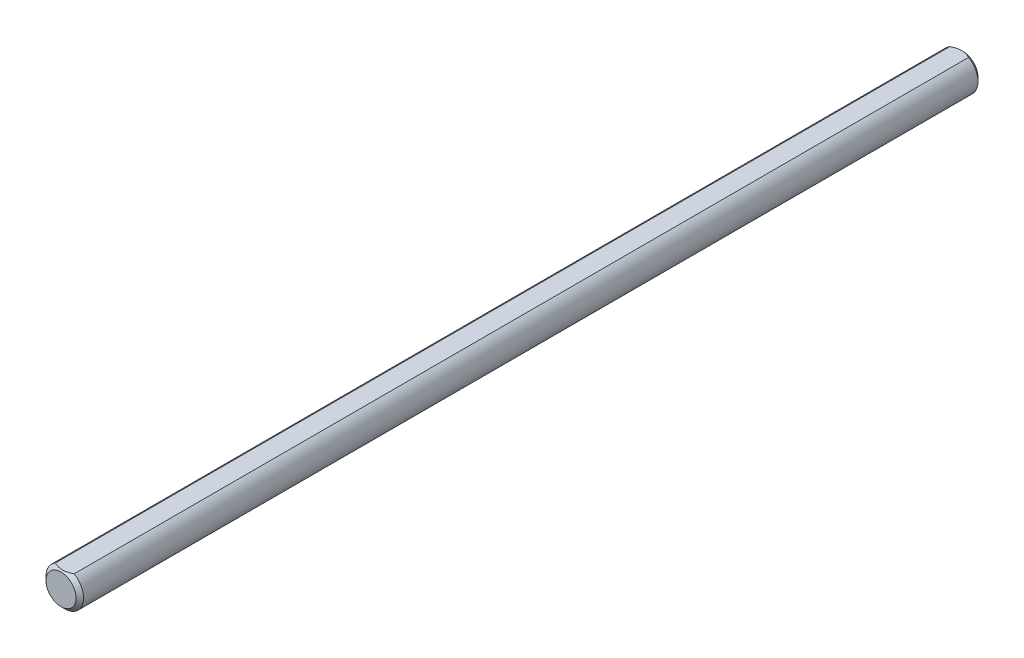
from build123d import *

# Parameters (mm, degrees)
SKETCH1_R           = 3.175
EXTRUDE1_DEPTH      = 76.2
CHAMFER1_SIZE       = 0.635
EXTRUDE7_DEPTH      = 77.2
EXTRUDE7_DEPTH_BACK = 77.2


with BuildPart() as part:
    # Sketch1 → Extrude1 (new body, symmetric)
    with BuildSketch(Plane.XY):
        Circle(SKETCH1_R)
    extrude(amount=EXTRUDE1_DEPTH, both=True)

    # Chamfer1
    chamfer1_edges = [part.edges().sort_by_distance(p)[0] for p in [
        (-3.175, 0, -76.2),
        (-3.175, 0, 76.2),
    ]]
    chamfer(chamfer1_edges, length=CHAMFER1_SIZE)

    # Sketch13 → Extrude7 (cut, two sides)
    with BuildSketch(Plane.XY) as extrude7_sk:
        with BuildLine():
            Line((-1.5875, 2.749630657), (1.5875, 2.749630657))
            ThreePointArc((1.5875, 2.749630657), (0, 3.175), (-1.5875, 2.749630657))
        make_face()
    extrude(amount=EXTRUDE7_DEPTH, mode=Mode.SUBTRACT)
    extrude(extrude7_sk.sketch, amount=-EXTRUDE7_DEPTH_BACK, mode=Mode.SUBTRACT)


solid = part.part
